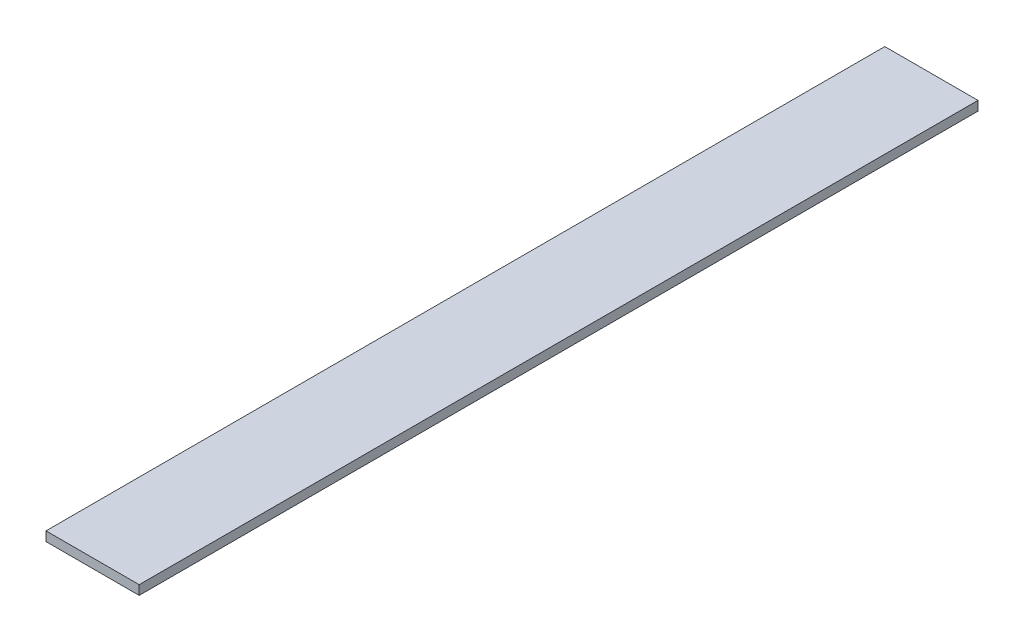
from build123d import *

# Parameters (mm, degrees)
SKETCH1_W           = 50.8
SKETCH1_H           = 457.2
BOSS_EXTRUDE1_DEPTH = 5.08


with BuildPart() as part:
    # Sketch1 → Boss-Extrude1 (new body)
    with BuildSketch(Plane(origin=(0, 0, 0), x_dir=(1, 0, 0), z_dir=(0, 1, 0))):
        with Locations((-25.4, 228.6)):
            Rectangle(SKETCH1_W, SKETCH1_H)
    extrude(amount=BOSS_EXTRUDE1_DEPTH)


solid = part.part
